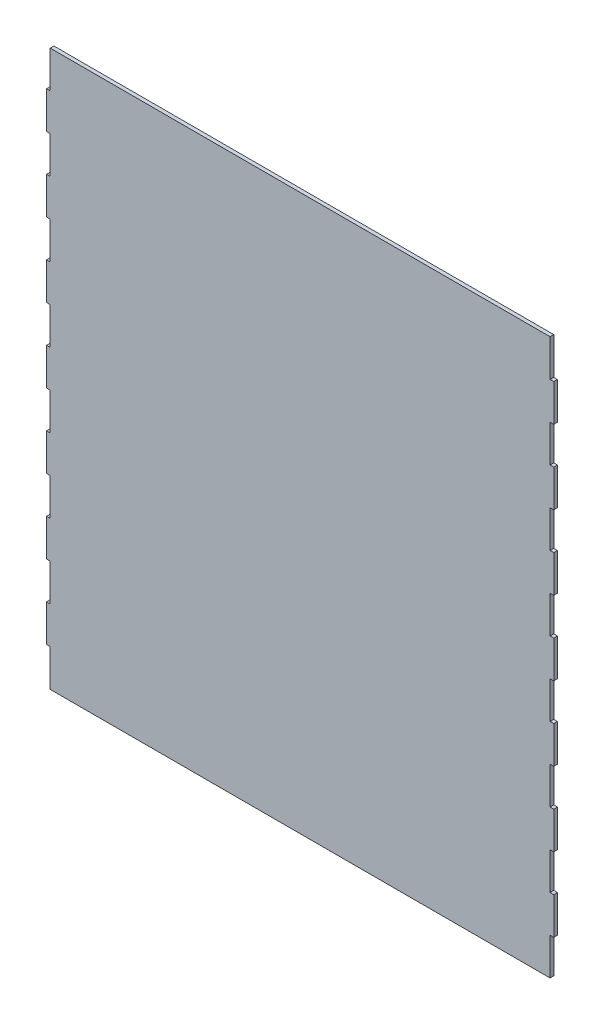
from build123d import *

# Parameters (mm, degrees)
SKETCH1_W               = 274
SKETCH1_H               = 300
BOSS_EXTRUDE1_DEPTH     = 2
SKETCH2_W               = 2
SKETCH2_H               = 20
CUT_EXTRUDE1_DEPTH      = 4
LPATTERN1_COUNT         = 8
LPATTERN1_PITCH         = 40
MIRROR1_COPY_1_SKETCH_W = 2
MIRROR1_COPY_1_SKETCH_H = 20
MIRROR1_COPY_1_DEPTH    = 4
MIRROR1_COPY_2_SKETCH_W = 2
MIRROR1_COPY_2_SKETCH_H = 20
MIRROR1_COPY_2_DEPTH    = 4
MIRROR1_COPY_3_SKETCH_W = 2
MIRROR1_COPY_3_SKETCH_H = 20
MIRROR1_COPY_3_DEPTH    = 4
MIRROR1_COPY_4_SKETCH_W = 2
MIRROR1_COPY_4_SKETCH_H = 20
MIRROR1_COPY_4_DEPTH    = 4
MIRROR1_COPY_5_SKETCH_W = 2
MIRROR1_COPY_5_SKETCH_H = 20
MIRROR1_COPY_5_DEPTH    = 4
MIRROR1_COPY_6_SKETCH_W = 2
MIRROR1_COPY_6_SKETCH_H = 20
MIRROR1_COPY_6_DEPTH    = 4
MIRROR1_COPY_7_SKETCH_W = 2
MIRROR1_COPY_7_SKETCH_H = 20
MIRROR1_COPY_7_DEPTH    = 4


with BuildPart() as part:
    # Sketch1 → Boss-Extrude1 (new body)
    with BuildSketch(Plane.XY):
        with Locations((-24.689291101, -42.156862745)):
            Rectangle(SKETCH1_W, SKETCH1_H)
    extrude(amount=BOSS_EXTRUDE1_DEPTH)

    # Sketch2 → Cut-Extrude1 (cut)
    with BuildSketch(Plane.XY.offset(2)):
        with Locations((-160.689291101, 97.843137255)):
            Rectangle(SKETCH2_W, SKETCH2_H)
    cut_extrude1 = extrude(amount=-CUT_EXTRUDE1_DEPTH, mode=Mode.SUBTRACT)

    # LPattern1: Cut-Extrude1 ×8
    with Locations(*[(0, -i * LPATTERN1_PITCH, 0) for i in range(1, LPATTERN1_COUNT)]):
        add(cut_extrude1, mode=Mode.SUBTRACT)

    # Mirror1: Cut-Extrude1 across plane
    add(cut_extrude1.mirror(Plane.ZY.offset(24.689291101)), mode=Mode.SUBTRACT)

    # Mirror1 copy 1 sketch → Mirror1 copy 1 (cut)
    with BuildSketch(Plane(origin=(-49.378582202, -40, 2), x_dir=(-1, 0, 0), z_dir=(0, 0, 1))):
        with Locations((-160.689291101, -97.843137255)):
            Rectangle(MIRROR1_COPY_1_SKETCH_W, MIRROR1_COPY_1_SKETCH_H)
    extrude(amount=-MIRROR1_COPY_1_DEPTH, mode=Mode.SUBTRACT)

    # Mirror1 copy 2 sketch → Mirror1 copy 2 (cut)
    with BuildSketch(Plane(origin=(-49.378582202, -80, 2), x_dir=(-1, 0, 0), z_dir=(0, 0, 1))):
        with Locations((-160.689291101, -97.843137255)):
            Rectangle(MIRROR1_COPY_2_SKETCH_W, MIRROR1_COPY_2_SKETCH_H)
    extrude(amount=-MIRROR1_COPY_2_DEPTH, mode=Mode.SUBTRACT)

    # Mirror1 copy 3 sketch → Mirror1 copy 3 (cut)
    with BuildSketch(Plane(origin=(-49.378582202, -120, 2), x_dir=(-1, 0, 0), z_dir=(0, 0, 1))):
        with Locations((-160.689291101, -97.843137255)):
            Rectangle(MIRROR1_COPY_3_SKETCH_W, MIRROR1_COPY_3_SKETCH_H)
    extrude(amount=-MIRROR1_COPY_3_DEPTH, mode=Mode.SUBTRACT)

    # Mirror1 copy 4 sketch → Mirror1 copy 4 (cut)
    with BuildSketch(Plane(origin=(-49.378582202, -160, 2), x_dir=(-1, 0, 0), z_dir=(0, 0, 1))):
        with Locations((-160.689291101, -97.843137255)):
            Rectangle(MIRROR1_COPY_4_SKETCH_W, MIRROR1_COPY_4_SKETCH_H)
    extrude(amount=-MIRROR1_COPY_4_DEPTH, mode=Mode.SUBTRACT)

    # Mirror1 copy 5 sketch → Mirror1 copy 5 (cut)
    with BuildSketch(Plane(origin=(-49.378582202, -200, 2), x_dir=(-1, 0, 0), z_dir=(0, 0, 1))):
        with Locations((-160.689291101, -97.843137255)):
            Rectangle(MIRROR1_COPY_5_SKETCH_W, MIRROR1_COPY_5_SKETCH_H)
    extrude(amount=-MIRROR1_COPY_5_DEPTH, mode=Mode.SUBTRACT)

    # Mirror1 copy 6 sketch → Mirror1 copy 6 (cut)
    with BuildSketch(Plane(origin=(-49.378582202, -240, 2), x_dir=(-1, 0, 0), z_dir=(0, 0, 1))):
        with Locations((-160.689291101, -97.843137255)):
            Rectangle(MIRROR1_COPY_6_SKETCH_W, MIRROR1_COPY_6_SKETCH_H)
    extrude(amount=-MIRROR1_COPY_6_DEPTH, mode=Mode.SUBTRACT)

    # Mirror1 copy 7 sketch → Mirror1 copy 7 (cut)
    with BuildSketch(Plane(origin=(-49.378582202, -280, 2), x_dir=(-1, 0, 0), z_dir=(0, 0, 1))):
        with Locations((-160.689291101, -97.843137255)):
            Rectangle(MIRROR1_COPY_7_SKETCH_W, MIRROR1_COPY_7_SKETCH_H)
    extrude(amount=-MIRROR1_COPY_7_DEPTH, mode=Mode.SUBTRACT)


solid = part.part
